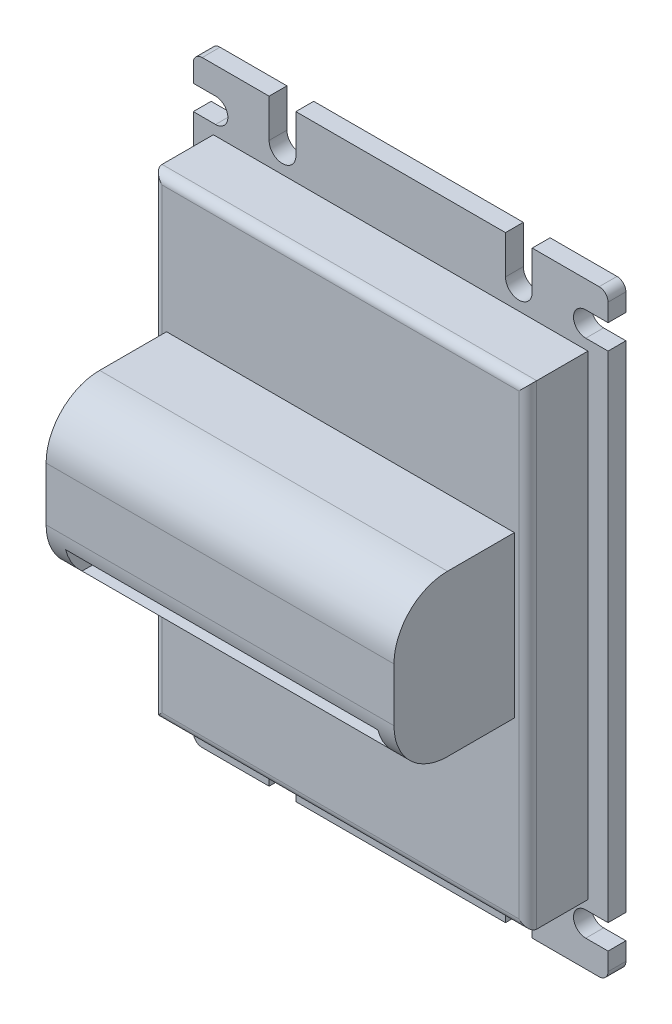
from build123d import *

# Parameters (mm, degrees)
SKETCH1_W           = 93
SKETCH1_H           = 134
BOSS_EXTRUDE1_DEPTH = 4
SKETCH2_W           = 88
SKETCH2_H           = 106.5
BOSS_EXTRUDE2_DEPTH = 13.5
FILLET2_R           = 2
SKETCH5_W           = 78
SKETCH5_H           = 36
BOSS_EXTRUDE3_DEPTH = 27
FILLET3_R           = 12
SKETCH6_W           = 70
SKETCH6_H           = 6
CUT_EXTRUDE1_DEPTH  = 45.5
SKETCH9_R           = 2.75
SKETCH9_W           = 5
SKETCH9_H           = 5.5
CUT_EXTRUDE3_DEPTH  = 10
CUT_EXTRUDE6_DEPTH  = 10
SKETCH13_W          = 2
SKETCH13_H          = 106.5
CUT_EXTRUDE7_DEPTH  = 13.5
FILLET4_R           = 2


with BuildPart() as part:
    # Sketch1 → Boss-Extrude1 (new body)
    with BuildSketch(Plane.XY):
        Rectangle(SKETCH1_W, SKETCH1_H)
    extrude(amount=BOSS_EXTRUDE1_DEPTH)

    # Sketch2 → Boss-Extrude2 (add)
    with BuildSketch(Plane.XY.offset(4)):
        Rectangle(SKETCH2_W, SKETCH2_H)
    extrude(amount=BOSS_EXTRUDE2_DEPTH)

    # Fillet2
    fillet2_edges = [part.edges().sort_by_distance(p)[0] for p in [
        (46.5, -67, 2),
        (-46.5, -67, 2),
        (-46.5, 67, 2),
        (46.5, 67, 2),
    ]]
    fillet(fillet2_edges, radius=FILLET2_R)

    # Sketch5 → Boss-Extrude3 (add)
    with BuildSketch(Plane.XY.offset(17.5)):
        with Locations((0, 5.25)):
            Rectangle(SKETCH5_W, SKETCH5_H)
    extrude(amount=BOSS_EXTRUDE3_DEPTH)

    # Fillet3
    fillet3_edges = [part.edges().sort_by_distance(p)[0] for p in [
        (0, 23.25, 44.5),
        (0, -12.75, 44.5),
    ]]
    fillet(fillet3_edges, radius=FILLET3_R)

    # Sketch6 → Cut-Extrude1 (cut, through all)
    with BuildSketch(Plane.XY.offset(44.5)):
        with Locations((0, -6.75)):
            Rectangle(SKETCH6_W, SKETCH6_H)
    extrude(amount=-CUT_EXTRUDE1_DEPTH, mode=Mode.SUBTRACT)

    # Sketch9 → Cut-Extrude3 (cut)
    with BuildSketch(Plane.XY.offset(4)):
        with Locations((41.5, 58.25)):
            Circle(SKETCH9_R)
        with Locations((-41.5, 58.25)):
            Circle(SKETCH9_R)
        with Locations((-41.5, -58.25)):
            Circle(SKETCH9_R)
        with Locations((41.5, -58.25)):
            Circle(SKETCH9_R)
        with Locations((44, 58.25)):
            Rectangle(SKETCH9_W, SKETCH9_H)
        with Locations((-44, 58.25)):
            Rectangle(SKETCH9_W, SKETCH9_H)
        with Locations((-44, -58.25)):
            Rectangle(SKETCH9_W, SKETCH9_H)
        with Locations((44, -58.25)):
            Rectangle(SKETCH9_W, SKETCH9_H)
    extrude(amount=-CUT_EXTRUDE3_DEPTH, mode=Mode.SUBTRACT)

    # Sketch8 → Cut-Extrude6 (cut)
    with BuildSketch(Plane.XY.offset(4)):
        with BuildLine():
            Line((29.5, 67), (23.5, 67))
            Line((23.5, 67), (23.5, 58.4))
            ThreePointArc((23.5, 58.4), (26.5, 55.4), (29.5, 58.4))
            Line((29.5, 58.4), (29.5, 67))
        make_face()
        with BuildLine():
            ThreePointArc((-29.5, 58.4), (-26.5, 55.4), (-23.5, 58.4))
            Line((-23.5, 58.4), (-23.5, 67))
            Line((-23.5, 67), (-29.5, 67))
            Line((-29.5, 67), (-29.5, 58.4))
        make_face()
        with BuildLine():
            Line((-29.5, -67), (-23.5, -67))
            Line((-23.5, -67), (-23.5, -58.4))
            ThreePointArc((-23.5, -58.4), (-26.5, -55.4), (-29.5, -58.4))
            Line((-29.5, -58.4), (-29.5, -67))
        make_face()
        with BuildLine():
            ThreePointArc((29.5, -58.4), (26.5, -55.4), (23.5, -58.4))
            Line((23.5, -58.4), (23.5, -67))
            Line((23.5, -67), (29.5, -67))
            Line((29.5, -67), (29.5, -58.4))
        make_face()
    extrude(amount=-CUT_EXTRUDE6_DEPTH, mode=Mode.SUBTRACT)

    # Sketch13 → Cut-Extrude7 (cut)
    with BuildSketch(Plane.XY.offset(17.5)):
        with Locations((-43, 0)):
            Rectangle(SKETCH13_W, SKETCH13_H)
        with Locations((43, 0)):
            Rectangle(SKETCH13_W, SKETCH13_H)
    extrude(amount=-CUT_EXTRUDE7_DEPTH, mode=Mode.SUBTRACT)

    # Fillet4
    fillet4_edges = [part.edges().sort_by_distance(p)[0] for p in [
        (0, 53.25, 17.5),
        (0, -53.25, 17.5),
        (-42, 0, 17.5),
        (42, 0, 17.5),
    ]]
    fillet(fillet4_edges, radius=FILLET4_R)


solid = part.part
